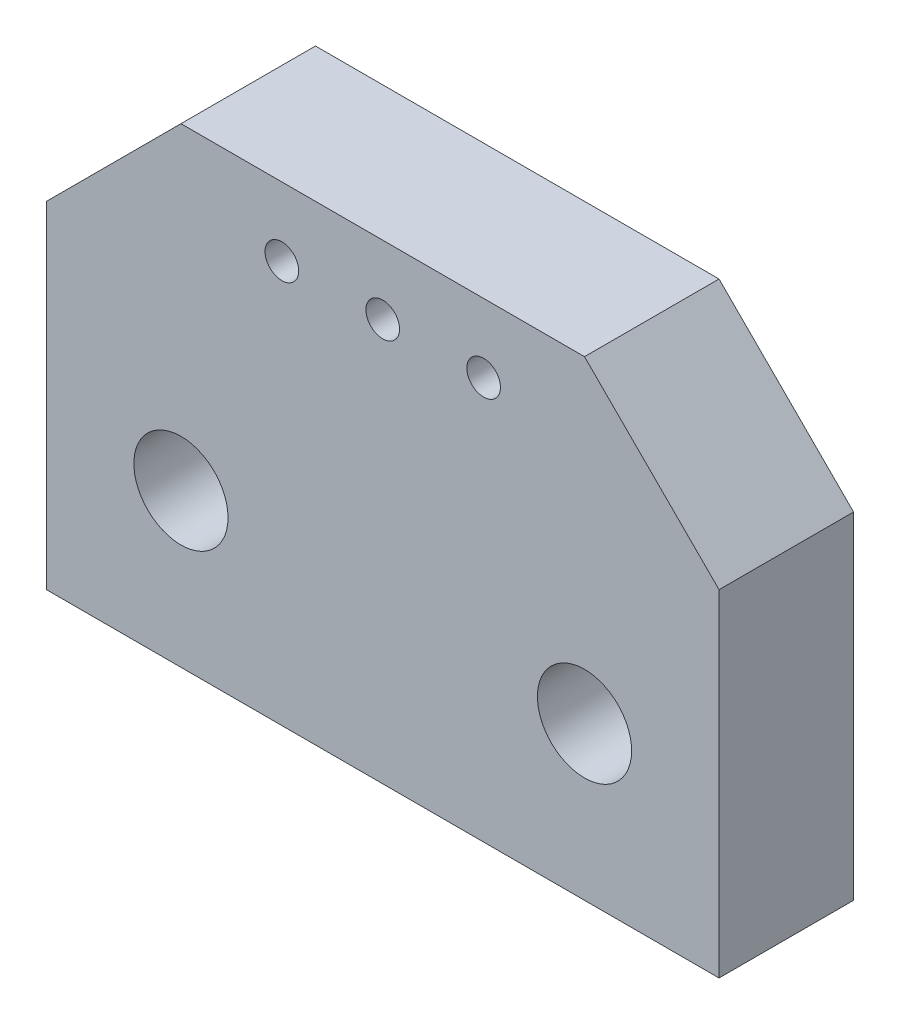
from build123d import *

# Parameters (mm, degrees)
BOSS_EXTRUDE1_DEPTH            = 2
F_1_4_1_4_DIAMETER_HOLE1_D     = 1.4
F_1_4_1_4_DIAMETER_HOLE1_DEPTH = 10
F_1_4_1_4_DIAMETER_HOLE1_TIP   = 0.420602433
F_0_5_0_5_DIAMETER_HOLE1_D     = 0.5
F_0_5_0_5_DIAMETER_HOLE1_DEPTH = 10
F_0_5_0_5_DIAMETER_HOLE1_TIP   = 0.150215155


with BuildPart() as part:
    # Sketch1 → Boss-Extrude1 (new body)
    with BuildSketch(Plane.XY):
        Polygon((1.097109919, 0), (1.097109919, 5), (3.097109919, 7), (9.097109919, 7), (11.097109919, 5), (11.097109919, 0), align=None)
    extrude(amount=BOSS_EXTRUDE1_DEPTH)

    # Ø1.4 (1.4) Diameter Hole1
    with Locations(Plane.XY.offset(2)):
        with Locations((3.097109919, 2.27502281), (9.097109919, 2.27502281)):
            Hole(F_1_4_1_4_DIAMETER_HOLE1_D / 2, depth=F_1_4_1_4_DIAMETER_HOLE1_DEPTH)
            with Locations((0, 0, -(F_1_4_1_4_DIAMETER_HOLE1_DEPTH + F_1_4_1_4_DIAMETER_HOLE1_TIP / 2))):  # 118° drill point
                Cone(0, F_1_4_1_4_DIAMETER_HOLE1_D / 2, F_1_4_1_4_DIAMETER_HOLE1_TIP, mode=Mode.SUBTRACT)

    # Ø0.5 (0.5) Diameter Hole1
    with Locations(Plane.XY.offset(2)):
        with Locations((6.097109919, 5.979300112), (4.597109919, 5.979300112), (7.597109919, 5.979300112)):
            Hole(F_0_5_0_5_DIAMETER_HOLE1_D / 2, depth=F_0_5_0_5_DIAMETER_HOLE1_DEPTH)
            with Locations((0, 0, -(F_0_5_0_5_DIAMETER_HOLE1_DEPTH + F_0_5_0_5_DIAMETER_HOLE1_TIP / 2))):  # 118° drill point
                Cone(0, F_0_5_0_5_DIAMETER_HOLE1_D / 2, F_0_5_0_5_DIAMETER_HOLE1_TIP, mode=Mode.SUBTRACT)


solid = part.part
